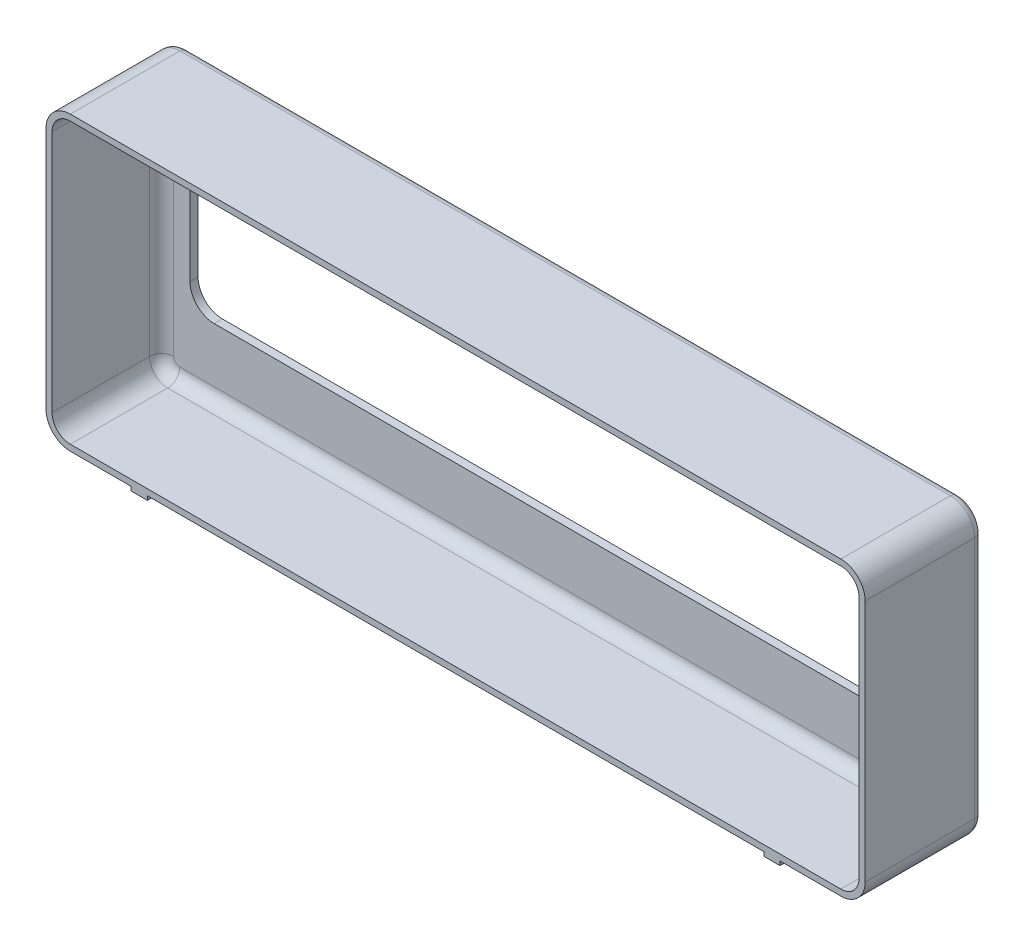
from build123d import *

# Parameters (mm, degrees)
SKETCH1_W           = 202
SKETCH1_H           = 72
BOSS_EXTRUDE1_DEPTH = 29
SKETCH2_W           = 199
SKETCH2_H           = 69
CUT_EXTRUDE1_DEPTH  = 27
SKETCH3_W           = 185
SKETCH3_H           = 37
CUT_EXTRUDE2_DEPTH  = 27
FILLET1_R           = 6
FILLET2_R           = 4.5
FILLET3_R           = 6
SKETCH4_W           = 4
SKETCH4_H           = 29
BOSS_EXTRUDE2_DEPTH = 1
FILLET4_R           = 2
FILLET5_R           = 3


with BuildPart() as part:
    # Sketch1 → Boss-Extrude1 (new body)
    with BuildSketch(Plane.XY):
        with Locations((101, 36)):
            Rectangle(SKETCH1_W, SKETCH1_H)
    extrude(amount=BOSS_EXTRUDE1_DEPTH)

    # Sketch2 → Cut-Extrude1 (cut)
    with BuildSketch(Plane.XY.offset(29)):
        with Locations((101, 36)):
            Rectangle(SKETCH2_W, SKETCH2_H)
    extrude(amount=-CUT_EXTRUDE1_DEPTH, mode=Mode.SUBTRACT)

    # Sketch3 → Cut-Extrude2 (cut)
    with BuildSketch(Plane.XY.offset(2)):
        with Locations((101, 36.5)):
            Rectangle(SKETCH3_W, SKETCH3_H)
    extrude(amount=-CUT_EXTRUDE2_DEPTH, mode=Mode.SUBTRACT)

    # Fillet1
    fillet1_edges = [part.edges().sort_by_distance(p)[0] for p in [
        (8.5, 18, 1),
        (8.5, 55, 1),
        (193.5, 55, 1),
        (193.5, 18, 1),
    ]]
    fillet(fillet1_edges, radius=FILLET1_R)

    # Fillet2
    fillet2_edges = [part.edges().sort_by_distance(p)[0] for p in [
        (1.5, 1.5, 15.5),
        (1.5, 70.5, 15.5),
        (200.5, 70.5, 15.5),
        (200.5, 1.5, 15.5),
    ]]
    fillet(fillet2_edges, radius=FILLET2_R)

    # Fillet3
    fillet3_edges = [part.edges().sort_by_distance(p)[0] for p in [
        (0, 72, 14.5),
        (202, 72, 14.5),
        (202, 0, 14.5),
        (0, 0, 14.5),
    ]]
    fillet(fillet3_edges, radius=FILLET3_R)

    # Sketch4 → Boss-Extrude2 (add)
    with BuildSketch(Plane(origin=(0, 0, 0), x_dir=(-1, 0, 0), z_dir=(0, -1, 0))):
        with Locations((-23, -14.5)):
            Rectangle(SKETCH4_W, SKETCH4_H)
        with Locations((-179, -14.5)):
            Rectangle(SKETCH4_W, SKETCH4_H)
    extrude(amount=BOSS_EXTRUDE2_DEPTH)

    # Fillet4
    fillet4_edges = [part.edges().sort_by_distance(p)[0] for p in [
        (200.242640687, 1.757359313, 0),
        (188.5, 0, 0),
        (202, 36, 0),
        (0, 36, 0),
        (101, 72, 0),
        (13.5, 0, 0),
        (1.757359313, 70.242640687, 0),
        (1.757359313, 1.757359313, 0),
        (200.242640687, 70.242640687, 0),
    ]]
    fillet(fillet4_edges, radius=FILLET4_R)

    # Fillet5
    fillet5_edges = [part.edges().sort_by_distance(p)[0] for p in [
        (101, 70.5, 2),
        (200.5, 36, 2),
        (1.5, 36, 2),
        (101, 1.5, 2),
        (2.818019485, 69.181980515, 2),
        (2.818019485, 2.818019485, 2),
        (199.181980515, 2.818019485, 2),
        (199.181980515, 69.181980515, 2),
    ]]
    fillet(fillet5_edges, radius=FILLET5_R)


solid = part.part
